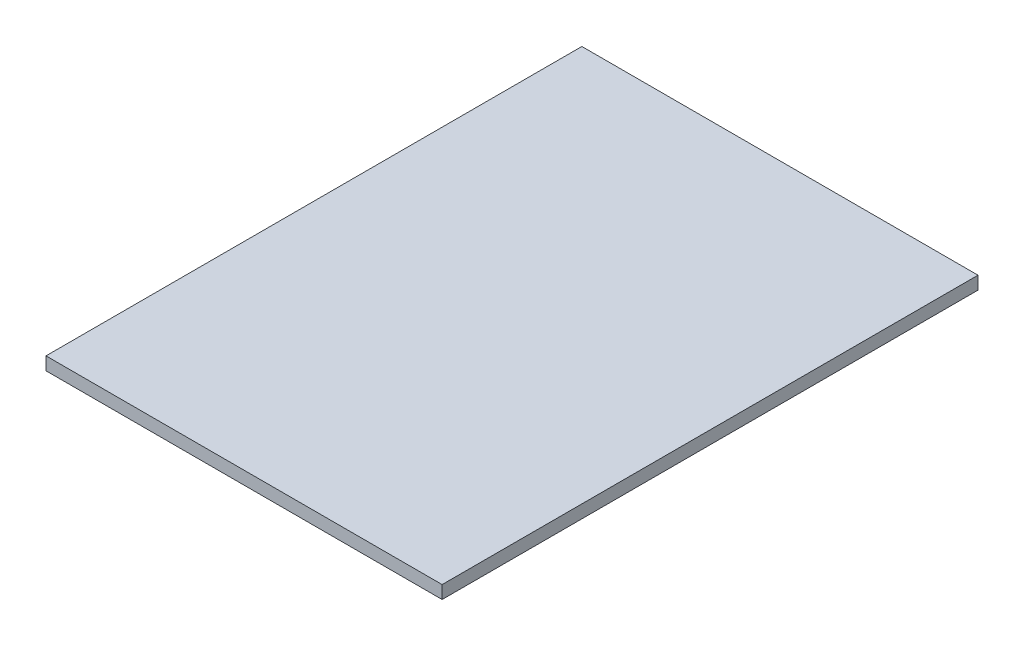
from build123d import *

# Parameters (mm, degrees)
SKETCH_1_W      = 550
SKETCH_1_H      = 744
EXTRUDE_1_DEPTH = 18


with BuildPart() as part:
    # Эскиз1 → Бобышка-Вытянуть1 (new body)
    with BuildSketch(Plane(origin=(0, 0, 0), x_dir=(1, 0, 0), z_dir=(0, 1, 0))):
        Rectangle(SKETCH_1_W, SKETCH_1_H)
    extrude(amount=EXTRUDE_1_DEPTH)


solid = part.part
